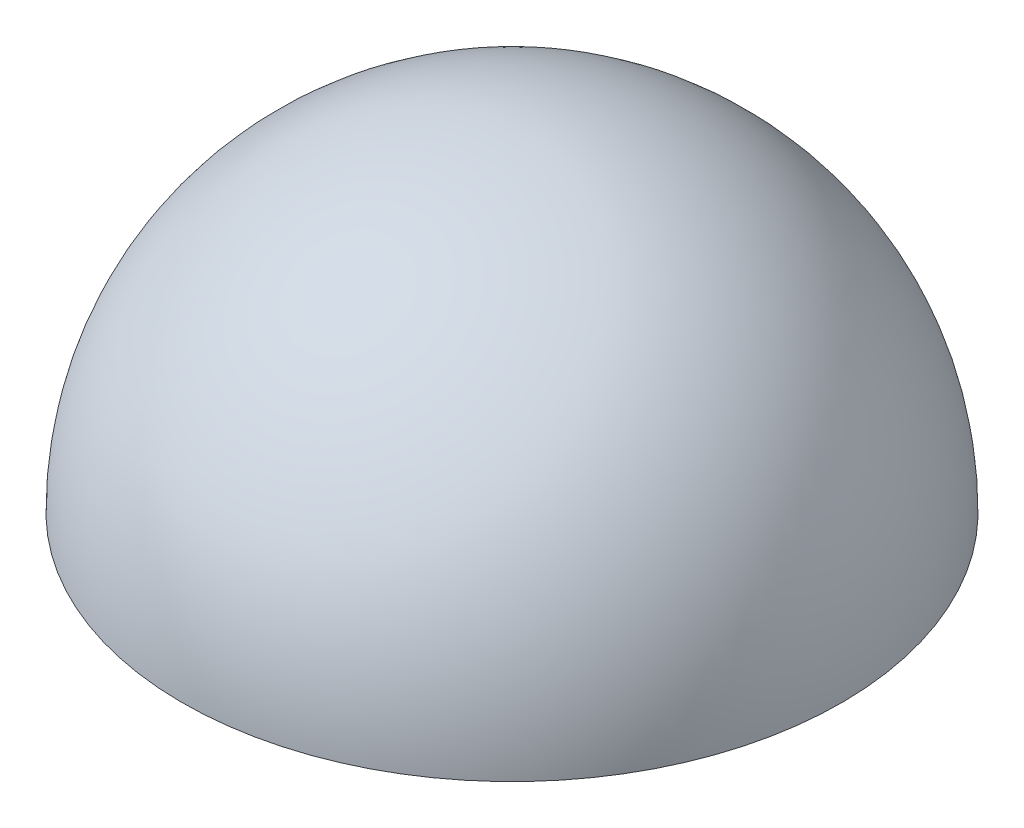
from build123d import *

# Parameters (mm, degrees)
REVOLVE1_ANGLE = 180


with BuildPart() as part:
    # Sketch1 → Revolve1 (revolve)
    with BuildSketch(Plane(origin=(0, 0, 0), x_dir=(1, 0, 0), z_dir=(0, 1, 0))):
        with BuildLine():
            ThreePointArc((44.192351352, 10.74901375), (21.093908516, 64.040565752), (-33.588943128, 83.618954657))
            Line((-33.588943128, 83.618954657), (-24.076354167, -62.120927157))
            ThreePointArc((-24.076354167, -62.120927157), (24.458903354, -39.177543414), (44.192351352, 10.74901375))
        make_face()
    revolve(axis=Axis((-33.588943128, 0, -83.618954657), (0.065132413, 0, 0.99787663)), revolution_arc=REVOLVE1_ANGLE)


solid = part.part
